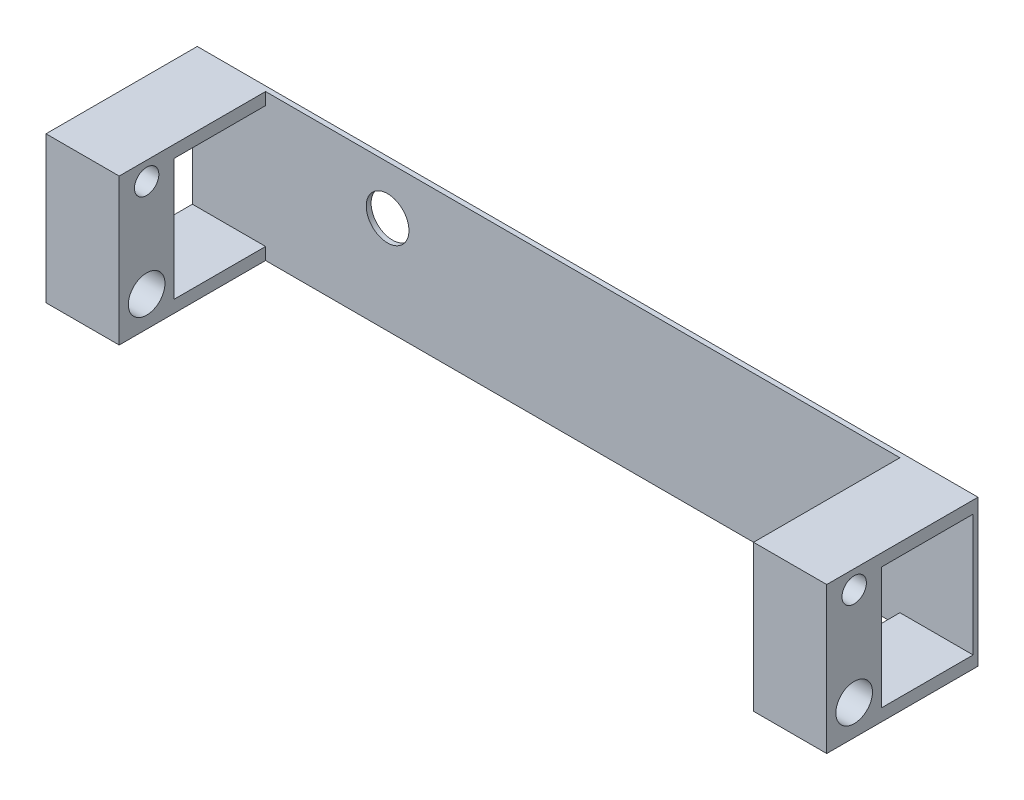
from build123d import *

# Parameters (mm, degrees)
SKETCH1_W           = 609.6
SKETCH1_H           = 76.2
SKETCH1_R           = 11.1125
BOSS_EXTRUDE1_DEPTH = 2.54
SKETCH2_W           = 38.1
SKETCH2_H           = 6.35
BOSS_EXTRUDE2_DEPTH = 76.2
SKETCH3_W           = 38.1
SKETCH3_H           = 76.2
BOSS_EXTRUDE3_DEPTH = 28.575
SKETCH4_R           = 6.35
SKETCH4_R_2         = 9.525
CUT_EXTRUDE1_DEPTH  = 610.6
SKETCH5_W           = 203.2
SKETCH5_H           = 76.2
CUT_EXTRUDE2_DEPTH  = 3.54


with BuildPart() as part:
    # Sketch1 → Boss-Extrude1 (new body)
    with BuildSketch(Plane.XY):
        with Locations((0, 21.113121982)):
            Rectangle(SKETCH1_W, SKETCH1_H)
        with Locations((0, 33.813121982)):
            Circle(SKETCH1_R, mode=Mode.SUBTRACT)
    extrude(amount=BOSS_EXTRUDE1_DEPTH)

    # Sketch2 → Boss-Extrude2 (add)
    with BuildSketch(Plane.XY.offset(2.54)):
        with Locations((-82.55, 56.038121982)):
            Rectangle(SKETCH2_W, SKETCH2_H)
        with Locations((-82.55, -13.811878018)):
            Rectangle(SKETCH2_W, SKETCH2_H)
        with Locations((285.75, 56.038121982)):
            Rectangle(SKETCH2_W, SKETCH2_H)
        with Locations((285.75, -13.811878018)):
            Rectangle(SKETCH2_W, SKETCH2_H)
    extrude(amount=BOSS_EXTRUDE2_DEPTH)

    # Sketch3 → Boss-Extrude3 (add)
    with BuildSketch(Plane.XY.offset(78.74)):
        with Locations((-82.55, 21.113121982)):
            Rectangle(SKETCH3_W, SKETCH3_H)
        with Locations((285.75, 21.113121982)):
            Rectangle(SKETCH3_W, SKETCH3_H)
    extrude(amount=-BOSS_EXTRUDE3_DEPTH)

    # Sketch4 → Cut-Extrude1 (cut, through all)
    with BuildSketch(Plane(origin=(304.8, 0, 0), x_dir=(0, 0, -1), z_dir=(1, 0, 0))):
        with Locations((-64.4525, 49.688121982)):
            Circle(SKETCH4_R)
        with Locations((-64.4525, -1.111878018)):
            Circle(SKETCH4_R_2)
    extrude(amount=-CUT_EXTRUDE1_DEPTH, mode=Mode.SUBTRACT)

    # Sketch5 → Cut-Extrude2 (cut, through all)
    with BuildSketch(Plane.XY.offset(2.54)):
        with Locations((-203.2, 21.113121982)):
            Rectangle(SKETCH5_W, SKETCH5_H)
    extrude(amount=-CUT_EXTRUDE2_DEPTH, mode=Mode.SUBTRACT)


solid = part.part
